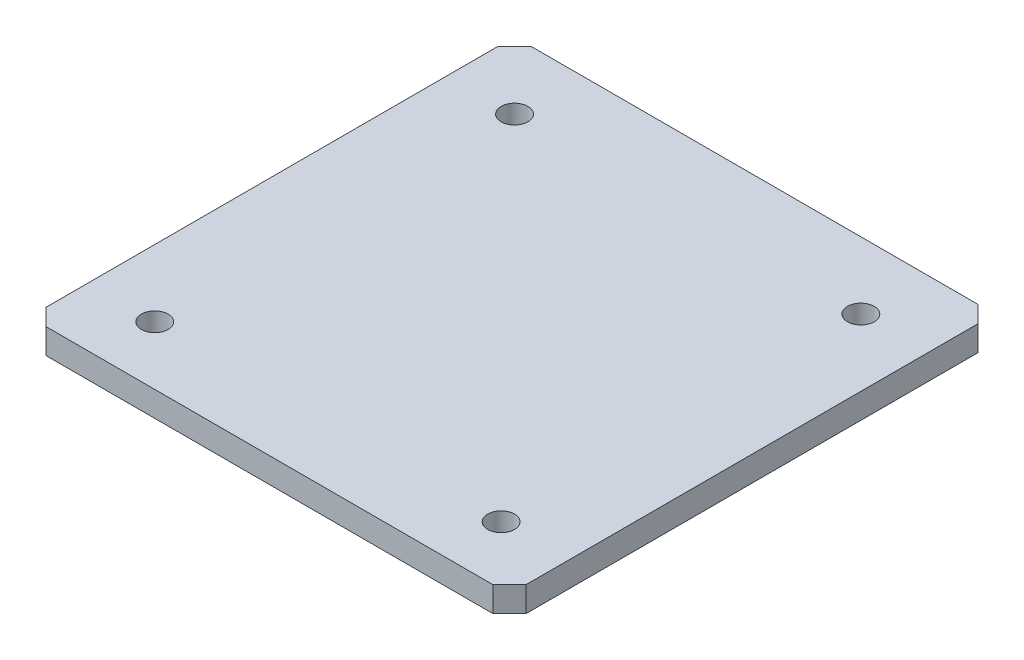
from build123d import *

# Parameters (mm, degrees)
SKETCH1_W           = 287
SKETCH1_H           = 290
BOSS_EXTRUDE1_DEPTH = 7.5
CHAMFER1_SIZE       = 10
SKETCH3_R           = 8
CUT_EXTRUDE1_DEPTH  = 16


with BuildPart() as part:
    # Sketch1 → Boss-Extrude1 (new body, symmetric)
    with BuildSketch(Plane(origin=(0, 0, 0), x_dir=(1, 0, 0), z_dir=(0, 1, 0))):
        with Locations((143.5, 145)):
            Rectangle(SKETCH1_W, SKETCH1_H)
    extrude(amount=BOSS_EXTRUDE1_DEPTH, both=True)

    # Chamfer1
    chamfer1_edges = [part.edges().sort_by_distance(p)[0] for p in [
        (0, 0, -290),
        (287, 0, -290),
        (287, 0, 0),
        (0, 0, 0),
    ]]
    chamfer(chamfer1_edges, length=CHAMFER1_SIZE)

    # Sketch3 → Cut-Extrude1 (cut)
    with BuildSketch(Plane(origin=(0, 7.5, 0), x_dir=(1, 0, 0), z_dir=(0, 1, 0))):
        with Locations((40, 35)):
            Circle(SKETCH3_R)
        with Locations((40, 250)):
            Circle(SKETCH3_R)
        with Locations((247, 250)):
            Circle(SKETCH3_R)
        with Locations((247, 35)):
            Circle(SKETCH3_R)
    extrude(amount=-CUT_EXTRUDE1_DEPTH, mode=Mode.SUBTRACT)


solid = part.part
